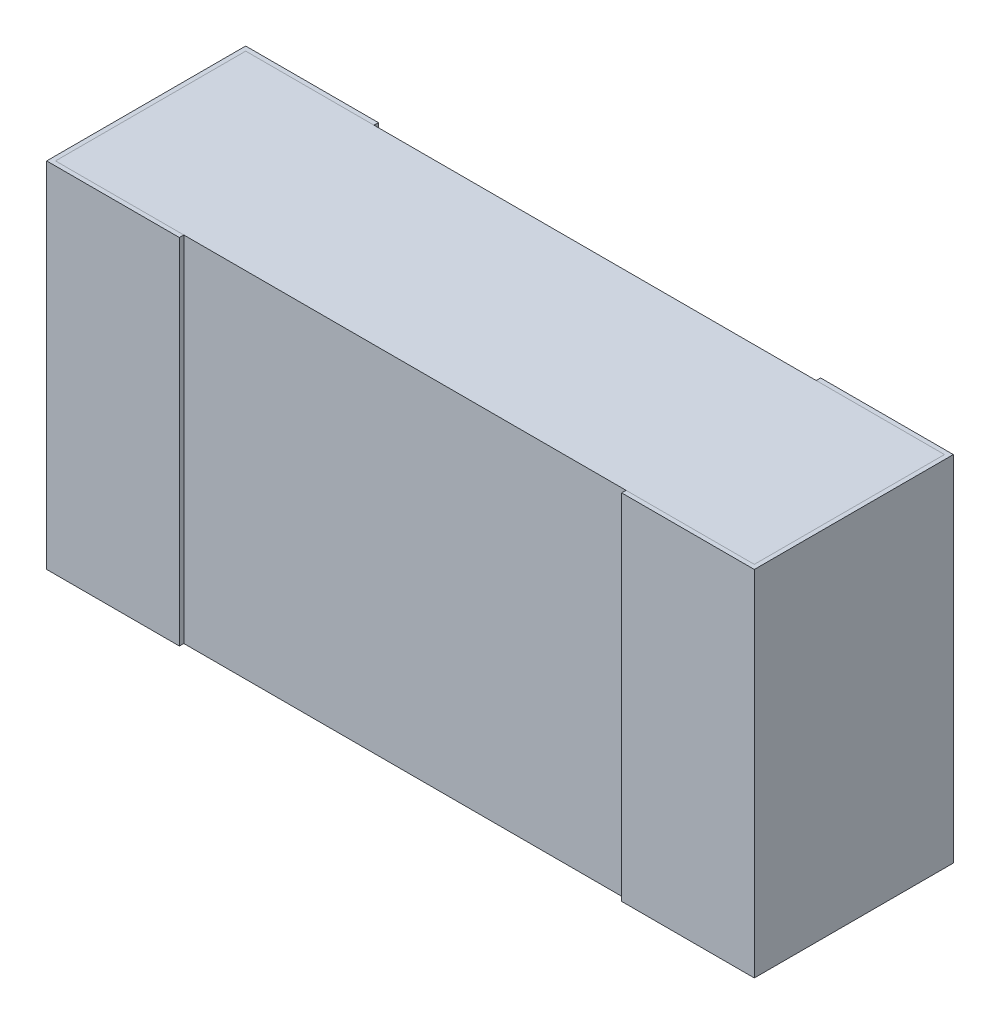
from build123d import *

# Parameters (mm, degrees)
BOSS_EXTRUDE2_DEPTH   = 0.4
BOSS_EXTRUDE2_2_DEPTH = 0.4
BOSS_EXTRUDE3_START   = -0.4
SKETCH5_W             = 0.43
SKETCH5_H             = 1.58
BOSS_EXTRUDE3_DEPTH   = 0.8


with BuildPart() as part:
    # Sketch4 → Boss-Extrude2 (new body, symmetric)
    with BuildSketch(Plane(origin=(0, 0, 0), x_dir=(-1, 0, 0), z_dir=(0, 1, 0))):
        Polygon((-0.8, -0.011612161), (-0.8, -0.461612161), (-0.5, -0.461612161), (-0.5, -0.451612161), (-0.79, -0.451612161), (-0.79, -0.021612161), (-0.5, -0.021612161), (-0.5, -0.011612161), align=None)
    extrude(amount=BOSS_EXTRUDE2_DEPTH, both=True)


with BuildPart() as body_2:
    # Sketch4 → Boss-Extrude2 2 (new body, symmetric)
    with BuildSketch(Plane(origin=(0, 0, 0), x_dir=(-1, 0, 0), z_dir=(0, 1, 0))):
        Polygon((0.5, -0.011612161), (0.8, -0.011612161), (0.8, -0.461612161), (0.5, -0.461612161), (0.5, -0.451612161), (0.79, -0.451612161), (0.79, -0.021612161), (0.5, -0.021612161), align=None)
    extrude(amount=BOSS_EXTRUDE2_2_DEPTH, both=True)


with BuildPart() as body_3:
    # Sketch5 → Boss-Extrude3 (new body)
    with BuildSketch(Plane(origin=(0, 0, 0), x_dir=(0, 0, -1), z_dir=(0, 1, 0)).offset(BOSS_EXTRUDE3_START)):
        with Locations((0.236612161, 0)):
            Rectangle(SKETCH5_W, SKETCH5_H)
    extrude(amount=BOSS_EXTRUDE3_DEPTH)


solid = Compound([part.part, body_2.part, body_3.part])
